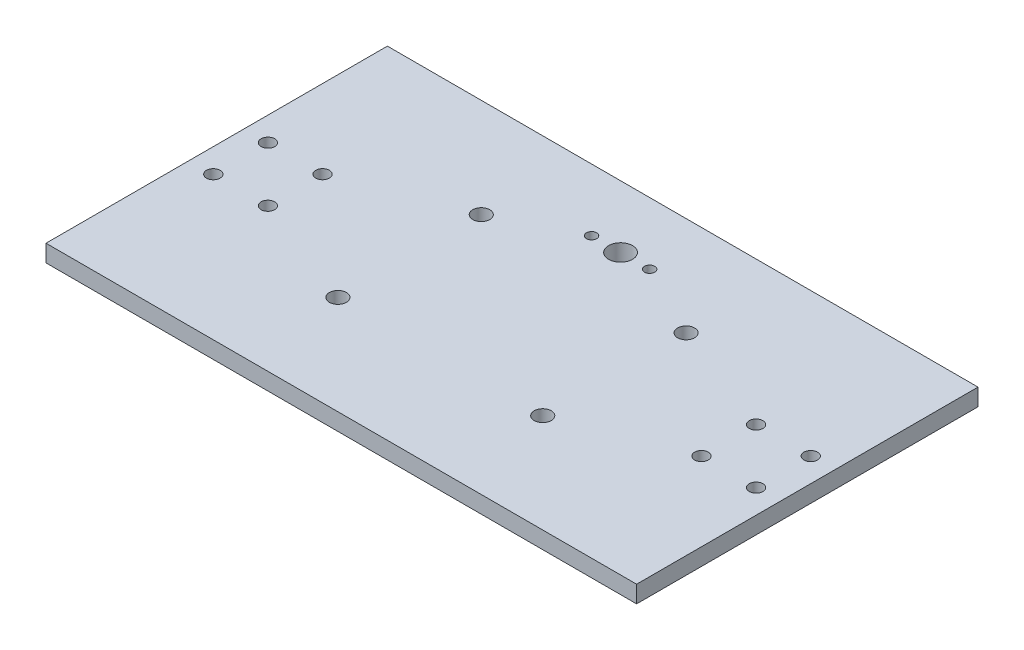
from build123d import *

# Parameters (mm, degrees)
SKETCH1_W           = 173
SKETCH1_H           = 100
SKETCH1_R           = 3.5
SKETCH1_R_2         = 1.5
SKETCH1_R_3         = 2.5
SKETCH1_R_4         = 2
BOSS_EXTRUDE1_DEPTH = 5


with BuildPart() as part:
    # Sketch1 → Boss-Extrude1 (new body)
    with BuildSketch(Plane(origin=(0, 0, 0), x_dir=(1, 0, 0), z_dir=(0, 1, 0))):
        with Locations((0, -31.8)):
            Rectangle(SKETCH1_W, SKETCH1_H)
        Circle(SKETCH1_R, mode=Mode.SUBTRACT)
        with Locations((-8.5, 0)):
            Circle(SKETCH1_R_2, mode=Mode.SUBTRACT)
        with Locations((8.5, 0)):
            Circle(SKETCH1_R_2, mode=Mode.SUBTRACT)
        with Locations((-30, -10.8)):
            Circle(SKETCH1_R_3, mode=Mode.SUBTRACT)
        with Locations((-30, -52.8)):
            Circle(SKETCH1_R_3, mode=Mode.SUBTRACT)
        with Locations((30, -52.8)):
            Circle(SKETCH1_R_3, mode=Mode.SUBTRACT)
        with Locations((30, -10.8)):
            Circle(SKETCH1_R_3, mode=Mode.SUBTRACT)
        with Locations((63.5, -23.8)):
            Circle(SKETCH1_R_4, mode=Mode.SUBTRACT)
        with Locations((79.5, -23.8)):
            Circle(SKETCH1_R_4, mode=Mode.SUBTRACT)
        with Locations((79.5, -39.8)):
            Circle(SKETCH1_R_4, mode=Mode.SUBTRACT)
        with Locations((63.5, -39.8)):
            Circle(SKETCH1_R_4, mode=Mode.SUBTRACT)
        with Locations((-63.5, -39.8)):
            Circle(SKETCH1_R_4, mode=Mode.SUBTRACT)
        with Locations((-79.5, -39.8)):
            Circle(SKETCH1_R_4, mode=Mode.SUBTRACT)
        with Locations((-79.5, -23.8)):
            Circle(SKETCH1_R_4, mode=Mode.SUBTRACT)
        with Locations((-63.5, -23.8)):
            Circle(SKETCH1_R_4, mode=Mode.SUBTRACT)
    extrude(amount=BOSS_EXTRUDE1_DEPTH)


solid = part.part
